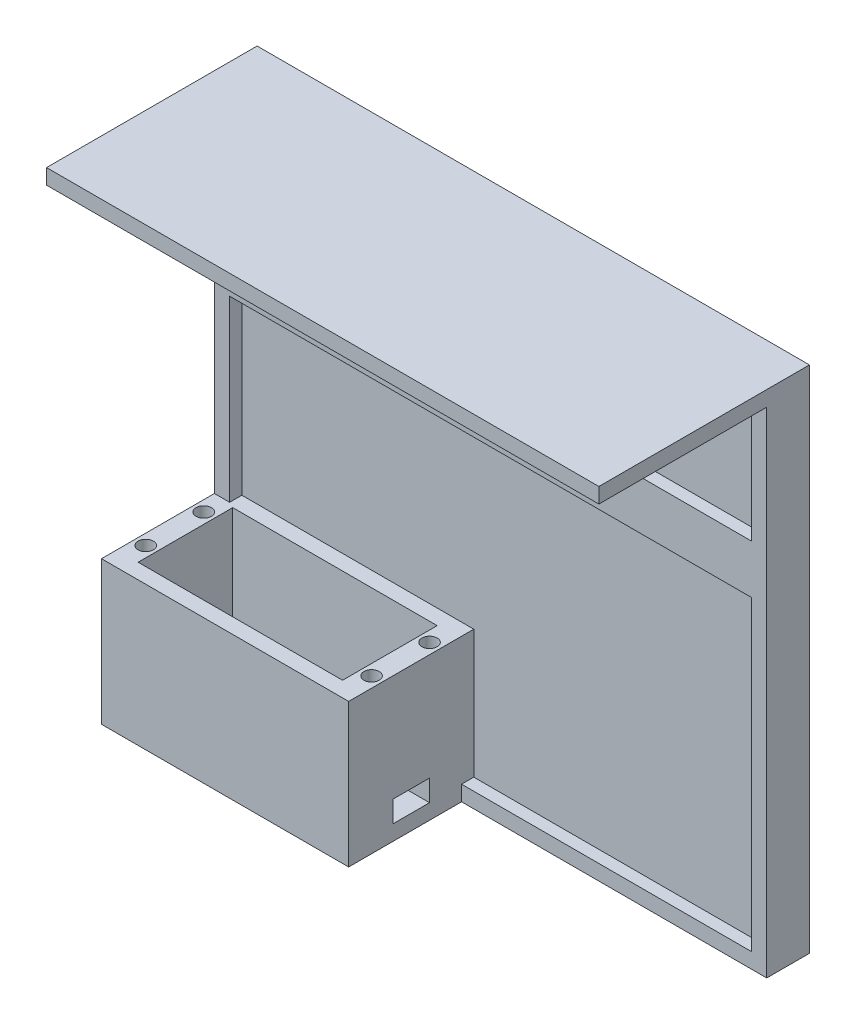
from build123d import *

# Parameters (mm, degrees)
SKETCH2_W                = 81
SKETCH2_H                = 41
SKETCH2_W_2              = 67
SKETCH2_H_2              = 31
BOSS_EXTRUDE1_DEPTH      = 42
BOSS_EXTRUDE1_DEPTH_BACK = 5
BOSS_EXTRUDE2_REACH      = 76
SKETCH3_W                = 31
SKETCH3_H                = 5
SKETCH4_R                = 2.5
CUT_EXTRUDE1_DEPTH       = 48
SKETCH5_W                = 12
SKETCH5_H                = 7
CUT_EXTRUDE2_DEPTH       = 20
SKETCH6_W                = 81
SKETCH6_H                = 47
BOSS_EXTRUDE3_DEPTH      = 10
SKETCH7_W                = 81
SKETCH7_H                = 10
BOSS_EXTRUDE4_DEPTH      = 120
SKETCH9_W                = 10
SKETCH9_H                = 167
BOSS_EXTRUDE6_DEPTH      = 100
SKETCH8_W                = 181
SKETCH8_H                = 16
BOSS_EXTRUDE5_DEPTH      = 4
SKETCH11_W               = 95
SKETCH11_H               = 5
SKETCH11_W_2             = 5
SKETCH11_H_2             = 100.5
SKETCH11_H_3             = 45.5
SKETCH11_W_3             = 181
SKETCH11_H_4             = 58.5
BOSS_EXTRUDE7_DEPTH      = 4
SKETCH12_W               = 181
SKETCH12_H               = 5
BOSS_EXTRUDE8_DEPTH      = 55


with BuildPart() as part:
    # Sketch2 → Boss-Extrude1 (new body, two sides)
    with BuildSketch(Plane(origin=(0, 0, 0), x_dir=(1, 0, 0), z_dir=(0, 1, 0))) as boss_extrude1_sk:
        Rectangle(SKETCH2_W, SKETCH2_H)
        Rectangle(SKETCH2_W_2, SKETCH2_H_2, mode=Mode.SUBTRACT)
    extrude(amount=BOSS_EXTRUDE1_DEPTH)
    extrude(boss_extrude1_sk.sketch, amount=-BOSS_EXTRUDE1_DEPTH_BACK)

    # Sketch3 → Boss-Extrude2 (add, up to next)
    with BuildSketch(Plane(origin=(-33.5, 0, 0), x_dir=(0, 0, -1), z_dir=(1, 0, 0)), mode=Mode.PRIVATE) as boss_extrude2_sk1:
        with Locations((0, -2.5)):
            Rectangle(SKETCH3_W, SKETCH3_H)
    boss_extrude2_tool1 = extrude(boss_extrude2_sk1.sketch, amount=BOSS_EXTRUDE2_REACH, mode=Mode.PRIVATE) - part.part
    add(boss_extrude2_tool1.solids().sort_by_distance((-33.5, -2.5, 0))[0])

    # Sketch4 → Cut-Extrude1 (cut, through all)
    with BuildSketch(Plane(origin=(0, 42, 0), x_dir=(1, 0, 0), z_dir=(0, 1, 0))):
        with Locations((-37, 9.5)):
            Circle(SKETCH4_R)
        with Locations((-37, -9.5)):
            Circle(SKETCH4_R)
    cut_extrude1 = extrude(amount=-CUT_EXTRUDE1_DEPTH, mode=Mode.SUBTRACT)

    # Sketch5 → Cut-Extrude2 (cut)
    with BuildSketch(Plane.ZY.offset(40.5)):
        with Locations((0, 3.5)):
            Rectangle(SKETCH5_W, SKETCH5_H)
    cut_extrude2 = extrude(amount=-CUT_EXTRUDE2_DEPTH, mode=Mode.SUBTRACT)

    # Mirror1: Cut-Extrude1, Cut-Extrude2 across plane
    add(cut_extrude1.mirror(Plane(origin=(0, 0, 0), x_dir=(0, 0, 1), z_dir=(1, 0, 0))), mode=Mode.SUBTRACT)
    add(cut_extrude2.mirror(Plane(origin=(0, 0, 0), x_dir=(0, 0, 1), z_dir=(1, 0, 0))), mode=Mode.SUBTRACT)

    # Sketch6 → Boss-Extrude3 (add)
    with BuildSketch(Plane(origin=(0, 0, -20.5), x_dir=(-1, 0, 0), z_dir=(0, 0, -1))):
        with Locations((0, 18.5)):
            Rectangle(SKETCH6_W, SKETCH6_H)
    extrude(amount=BOSS_EXTRUDE3_DEPTH)

    # Sketch7 → Boss-Extrude4 (add)
    with BuildSketch(Plane(origin=(0, 42, 0), x_dir=(1, 0, 0), z_dir=(0, 1, 0))):
        with Locations((0, 25.5)):
            Rectangle(SKETCH7_W, SKETCH7_H)
    extrude(amount=BOSS_EXTRUDE4_DEPTH)

    # Sketch9 → Boss-Extrude6 (add)
    with BuildSketch(Plane(origin=(40.5, 0, 0), x_dir=(0, 0, -1), z_dir=(1, 0, 0))):
        with Locations((25.5, 78.5)):
            Rectangle(SKETCH9_W, SKETCH9_H)
    extrude(amount=BOSS_EXTRUDE6_DEPTH)

    # Sketch8 → Boss-Extrude5 (add)
    with BuildSketch(Plane.XY.offset(-20.5)):
        with Locations((50, 108.5)):
            Rectangle(SKETCH8_W, SKETCH8_H)
    extrude(amount=BOSS_EXTRUDE5_DEPTH)

    # Sketch11 → Boss-Extrude7 (add)
    with BuildSketch(Plane.XY.offset(-20.5)):
        with Locations((88, -2.5)):
            Rectangle(SKETCH11_W, SKETCH11_H)
        with Locations((138, 50.25)):
            Rectangle(SKETCH11_W_2, SKETCH11_H_2)
        with Locations((138, -2.5)):
            Rectangle(SKETCH11_W_2, SKETCH11_H)
        with Locations((-38, 139.25)):
            Rectangle(SKETCH11_W_2, SKETCH11_H_3)
        with Locations((50, 159.5)):
            Rectangle(SKETCH11_W_3, SKETCH11_H)
        with Locations((138, 139.25)):
            Rectangle(SKETCH11_W_2, SKETCH11_H_3)
        with Locations((-38, 71.25)):
            Rectangle(SKETCH11_W_2, SKETCH11_H_4)
    extrude(amount=BOSS_EXTRUDE7_DEPTH)

    # Sketch12 → Boss-Extrude8 (add)
    with BuildSketch(Plane.XY.offset(-16.5)):
        with Locations((50, 159.5)):
            Rectangle(SKETCH12_W, SKETCH12_H)
    extrude(amount=BOSS_EXTRUDE8_DEPTH)


solid = part.part
